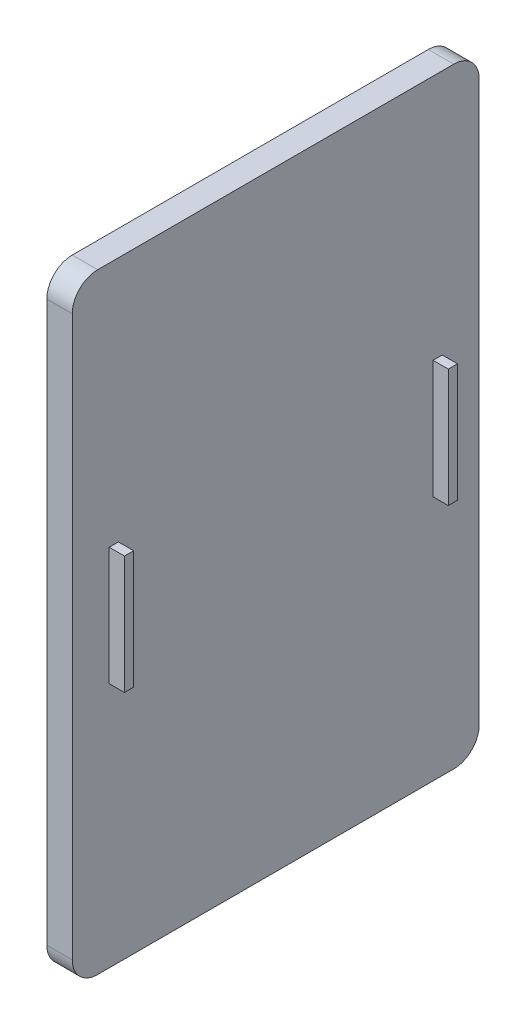
from build123d import *

# Parameters (mm, degrees)
SKETCH1_W           = 80
SKETCH1_H           = 120
BOSS_EXTRUDE1_DEPTH = 5
FILLET1_R           = 5
SKETCH2_W           = 1.804418344
SKETCH2_H           = 23.230636126
BOSS_EXTRUDE2_DEPTH = 3


with BuildPart() as part:
    # Sketch1 → Boss-Extrude1 (new body)
    with BuildSketch(Plane(origin=(0, 0, 0), x_dir=(0, 0, -1), z_dir=(1, 0, 0))):
        Rectangle(SKETCH1_W, SKETCH1_H)
    extrude(amount=BOSS_EXTRUDE1_DEPTH)

    # Fillet1
    fillet1_edges = [part.edges().sort_by_distance(p)[0] for p in [
        (2.5, -60, -40),
        (2.5, -60, 40),
        (2.5, 60, 40),
        (2.5, 60, -40),
    ]]
    fillet(fillet1_edges, radius=FILLET1_R)

    # Sketch2 → Boss-Extrude2 (add)
    with BuildSketch(Plane(origin=(5, 0, 0), x_dir=(0, 0, -1), z_dir=(1, 0, 0))):
        with Locations((-31.82671961, 0)):
            Rectangle(SKETCH2_W, SKETCH2_H)
    boss_extrude2 = extrude(amount=BOSS_EXTRUDE2_DEPTH)

    # Mirror1: Boss-Extrude2 across plane
    add(boss_extrude2.mirror(Plane.XY))


solid = part.part
